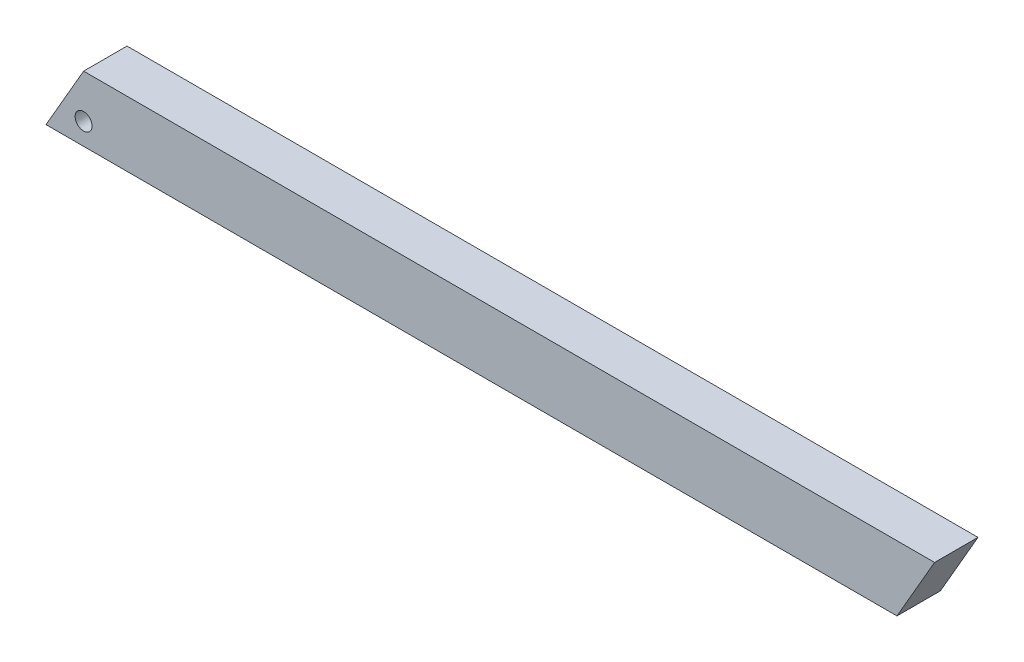
from build123d import *

# Parameters (mm, degrees)
SKETCH1_R           = 4.959529834
BOSS_EXTRUDE1_DEPTH = 25.4


with BuildPart() as part:
    # Sketch1 → Boss-Extrude1 (new body)
    with BuildSketch(Plane.XY):
        Polygon((248.868157838, 0), (237.86963521, -19.05), (-259.866680466, -19.05), (-248.868157838, 0), (-237.86963521, 19.05), (259.866680466, 19.05), align=None)
        with Locations((-237.86963521, -6.35)):
            Circle(SKETCH1_R, mode=Mode.SUBTRACT)
    extrude(amount=BOSS_EXTRUDE1_DEPTH)


solid = part.part
